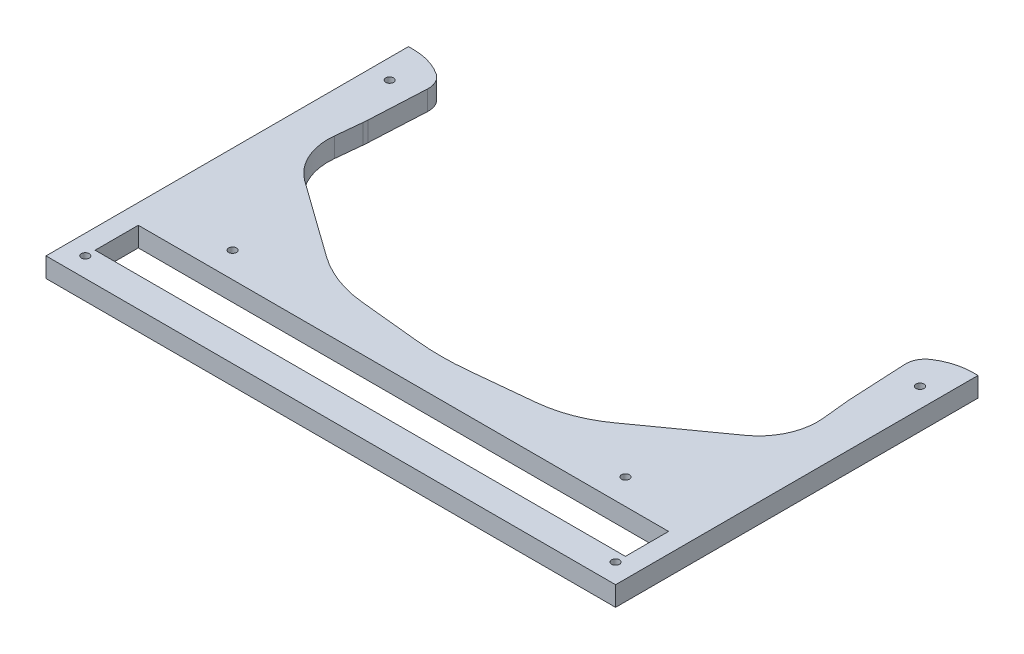
from build123d import *

# Parameters (mm, degrees)
BOSS_EXTRU_1_DEPTH       = 10
ESQUISSE3_R              = 2
ENL_V_MAT_EXTRU_1_DEPTH  = 10
ESQUISSE6_W              = 270
ESQUISSE6_H              = 22
ENL_V_MAT_EXTRU_4_DEPTH  = 10
ESQUISSE9_R              = 2
ENL_V_MAT_EXTRU_7_DEPTH  = 10
ENL_V_MAT_EXTRU_9_DEPTH  = 10
CONG_5_R                 = 10
ESQUISSE12_R             = 2
ENL_V_MAT_EXTRU_10_DEPTH = 10
ESQUISSE14_R             = 6
ENL_V_MAT_EXTRU_11_DEPTH = 5


with BuildPart() as part:
    # Esquisse2 → Boss.-Extru.1 (new body)
    with BuildSketch(Plane(origin=(0, 0, 0), x_dir=(1, 0, 0), z_dir=(0, 1, 0))):
        with BuildLine():
            Line((0, 0), (290, 0))
            Line((290, 0), (290, 184.53))
            Line((290, 184.53), (287.426406871, 184.53))
            ThreePointArc((287.426406871, 184.53), (275.9459039, 182.246385975), (266.213203436, 175.743203436))
            Line((266.213203436, 175.743203436), (180.47, 90))
            Line((180.47, 90), (109.53, 90))
            Line((109.53, 90), (23.786796564, 175.743203436))
            ThreePointArc((23.786796564, 175.743203436), (14.0540961, 182.246385975), (2.573593129, 184.53))
            Line((2.573593129, 184.53), (0, 184.53))
            Line((0, 184.53), (0, 0))
        make_face()
    extrude(amount=BOSS_EXTRU_1_DEPTH)

    # Esquisse3 → Enlèv. mat.-Extru.1 (cut)
    with BuildSketch(Plane(origin=(0, 10, 0), x_dir=(1, 0, 0), z_dir=(0, 1, 0))):
        with Locations((10, 10)):
            Circle(ESQUISSE3_R)
        with Locations((280, 10)):
            Circle(ESQUISSE3_R)
    extrude(amount=-ENL_V_MAT_EXTRU_1_DEPTH, mode=Mode.SUBTRACT)

    # Esquisse6 → Enlèv. mat.-Extru.4 (cut)
    with BuildSketch(Plane(origin=(0, 10, 0), x_dir=(1, 0, 0), z_dir=(0, 1, 0))):
        with Locations((145, 26)):
            Rectangle(ESQUISSE6_W, ESQUISSE6_H)
    extrude(amount=-ENL_V_MAT_EXTRU_4_DEPTH, mode=Mode.SUBTRACT)

    # Esquisse9 → Enlèv. mat.-Extru.7 (cut)
    with BuildSketch(Plane(origin=(0, 10, 0), x_dir=(1, 0, 0), z_dir=(0, 1, 0))):
        with Locations((45, 50)):
            Circle(ESQUISSE9_R)
        with Locations((245, 50)):
            Circle(ESQUISSE9_R)
    extrude(amount=-ENL_V_MAT_EXTRU_7_DEPTH, mode=Mode.SUBTRACT)

    # Esquisse11 → Enlèv. mat.-Extru.9 (cut)
    with BuildSketch(Plane.XZ):
        with BuildLine():
            Line((23.786796564, -175.743203436), (22.069258887, -141.969600166))
            ThreePointArc((22.069258887, -141.969600166), (21.990433689, -140.725538115), (21.88061952, -139.483827743))
            Line((21.88061952, -139.483827743), (20.54302042, -126.242335439))
            ThreePointArc((20.54302042, -126.242335439), (23.053468491, -110.871931551), (32.931464028, -98.831297457))
            Line((32.931464028, -98.831297457), (71.774958897, -71.031800705))
            ThreePointArc((71.774958897, -71.031800705), (85.505992048, -63.689345624), (100.664013996, -60.127423581))
            Line((100.664013996, -60.127423581), (131.934446663, -56.968617789))
            ThreePointArc((131.934446663, -56.968617789), (145, -56.310379475), (158.065553337, -56.968617789))
            Line((158.065553337, -56.968617789), (189.335986004, -60.127423581))
            ThreePointArc((189.335986004, -60.127423581), (204.494007952, -63.689345624), (218.225041103, -71.031800705))
            Line((218.225041103, -71.031800705), (257.068535972, -98.831297457))
            ThreePointArc((257.068535972, -98.831297457), (266.946531509, -110.871931551), (269.45697958, -126.242335439))
            Line((269.45697958, -126.242335439), (268.11938048, -139.483827743))
            ThreePointArc((268.11938048, -139.483827743), (268.009566311, -140.725538115), (267.930741113, -141.969600166))
            Line((267.930741113, -141.969600166), (266.213203436, -175.743203436))
            Line((266.213203436, -175.743203436), (23.786796564, -175.743203436))
        make_face()
    extrude(amount=-ENL_V_MAT_EXTRU_9_DEPTH, mode=Mode.SUBTRACT)

    # Congé5
    cong_5_edges = [part.edges().sort_by_distance(p)[0] for p in [
        (23.786796564, 5, -175.743203436),
        (266.213203436, 5, -175.743203436),
    ]]
    fillet(cong_5_edges, radius=CONG_5_R)

    # Esquisse12 → Enlèv. mat.-Extru.10 (cut)
    with BuildSketch(Plane.XZ):
        with Locations((10, -165)):
            Circle(ESQUISSE12_R)
        with Locations((280, -165)):
            Circle(ESQUISSE12_R)
    extrude(amount=-ENL_V_MAT_EXTRU_10_DEPTH, mode=Mode.SUBTRACT)

    # Esquisse14 → Enlèv. mat.-Extru.11 (cut)
    with BuildSketch(Plane.XZ):
        with Locations((10, -10)):
            Circle(ESQUISSE14_R)
        with Locations((45, -50)):
            Circle(ESQUISSE14_R)
        with Locations((10, -165)):
            Circle(ESQUISSE14_R)
        with Locations((280, -165)):
            Circle(ESQUISSE14_R)
        with Locations((245, -50)):
            Circle(ESQUISSE14_R)
        with Locations((280, -10)):
            Circle(ESQUISSE14_R)
    extrude(amount=-ENL_V_MAT_EXTRU_11_DEPTH, mode=Mode.SUBTRACT)


solid = part.part
